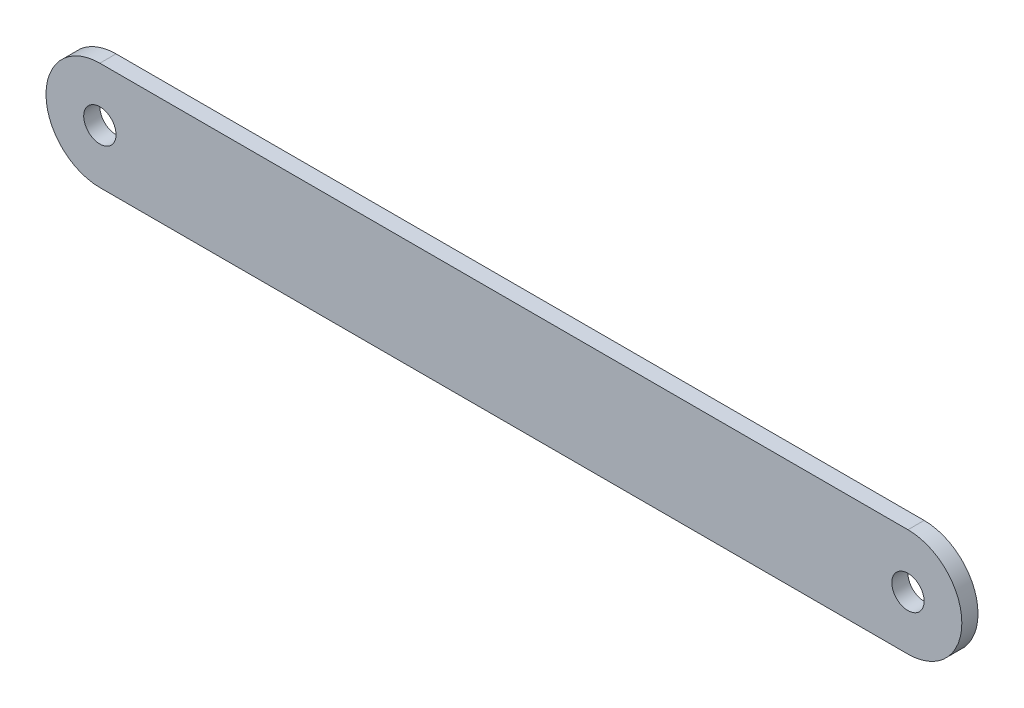
from build123d import *

# Parameters (mm, degrees)
SKETCH1_R           = 3
BOSS_EXTRUDE1_DEPTH = 3


with BuildPart() as part:
    # Sketch1 → Boss-Extrude1 (new body)
    with BuildSketch(Plane.XY):
        with BuildLine():
            Line((-75, -10), (75, -10))
            ThreePointArc((75, -10), (85, 0), (75, 10))
            Line((75, 10), (-75, 10))
            ThreePointArc((-75, 10), (-85, 0), (-75, -10))
        make_face()
        with Locations((-75, 0)):
            Circle(SKETCH1_R, mode=Mode.SUBTRACT)
        with Locations((75, 0)):
            Circle(SKETCH1_R, mode=Mode.SUBTRACT)
    extrude(amount=BOSS_EXTRUDE1_DEPTH)


solid = part.part
